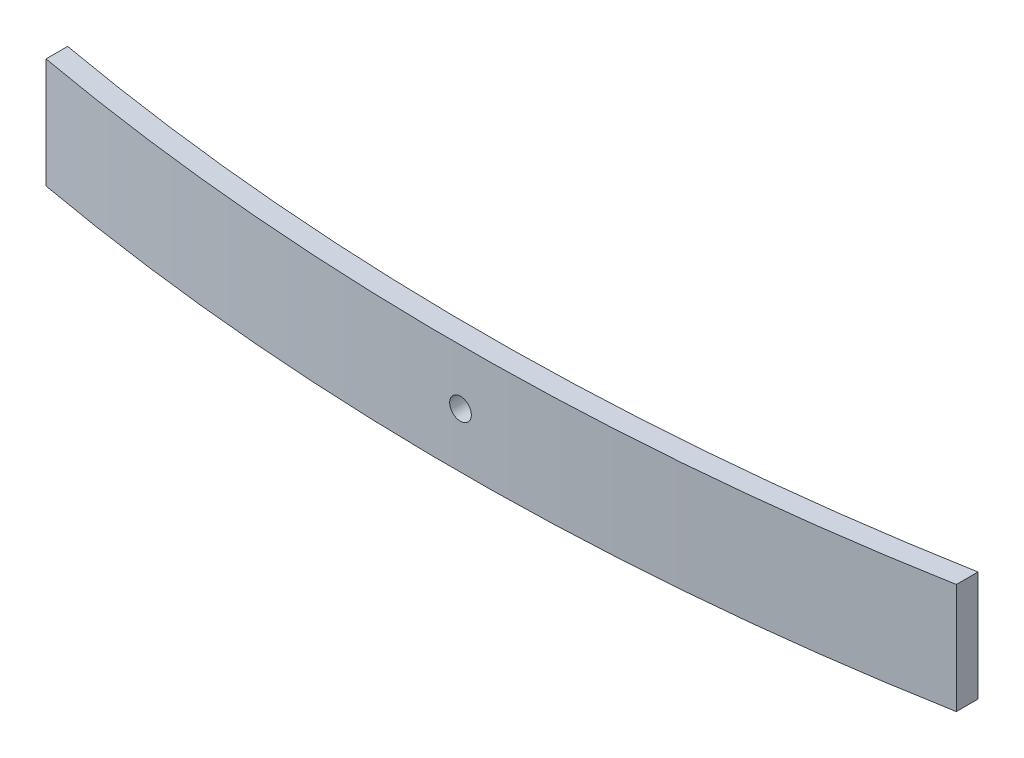
from build123d import *

# Parameters (mm, degrees)
BOSS_EXTRUDE1_DEPTH = 76.2
SKETCH11_R          = 7.5
CUT_EXTRUDE1_DEPTH  = 239


with BuildPart() as part:
    # Sketch1 → Boss-Extrude1 (new body)
    with BuildSketch(Plane(origin=(0, 0, 0), x_dir=(1, 0, 0), z_dir=(0, 1, 0))):
        with BuildLine():
            ThreePointArc((315.021699517, -194.83870643), (0, -223), (-315.021699517, -194.83870643))
            Line((-315.021699517, -194.83870643), (-315.021699517, -209.83870643))
            ThreePointArc((-315.021699517, -209.83870643), (0, -238), (315.021699517, -209.83870643))
            Line((315.021699517, -209.83870643), (315.021699517, -194.83870643))
        make_face()
    extrude(amount=BOSS_EXTRUDE1_DEPTH)

    # Sketch11 → Cut-Extrude1 (cut, through all)
    with BuildSketch(Plane.XY):
        with Locations((0, 38.1)):
            Circle(SKETCH11_R)
    extrude(amount=CUT_EXTRUDE1_DEPTH, mode=Mode.SUBTRACT)


solid = part.part
